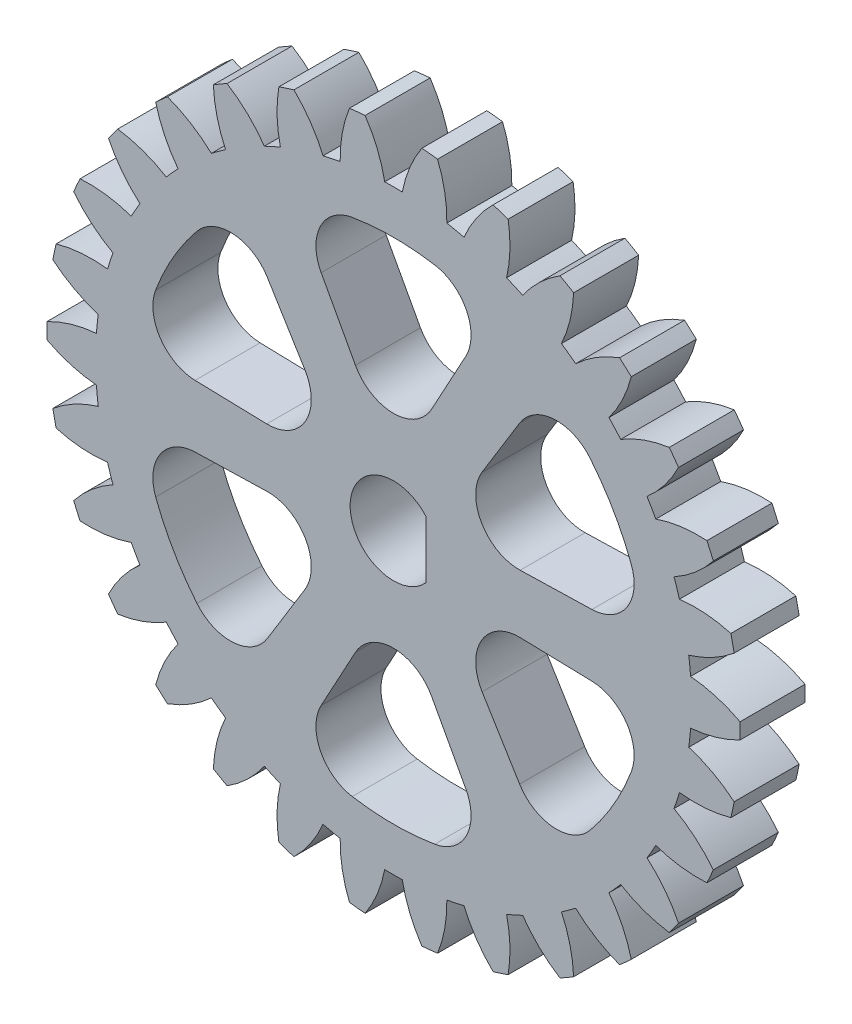
from build123d import *

# Parameters (mm, degrees)
SKETCH1_R                 = 16
BOSS_EXTRUDE1_DEPTH       = 3
CUT_EXTRUDE1_DEPTH        = 4
CIRPATTERN1_COUNT         = 30
CUT_EXTRUDE2_DEPTH        = 4
FILLET10_R                = 2
CIRPATTERN2_COUNT         = 6
FILLET10_OF_CIRPATTERN2_R = 2
CUT_EXTRUDE3_DEPTH        = 4


with BuildPart() as part:
    # Sketch1 → Boss-Extrude1 (new body)
    with BuildSketch(Plane.XY):
        Circle(SKETCH1_R)
    extrude(amount=BOSS_EXTRUDE1_DEPTH)

    # Sketch3 → Cut-Extrude1 (cut, through all)
    with BuildSketch(Plane.XY.offset(3)):
        with BuildLine():
            ThreePointArc((0.405262886, 13.744026411), (0, 13.75), (-0.405262886, 13.744026411))
            ThreePointArc((-0.405262886, 13.744026411), (-0.747286699, 14.890480207), (-1.309972212, 15.946283981))
            ThreePointArc((-1.309972212, 15.946283981), (0, 16), (1.309972212, 15.946283981))
            ThreePointArc((1.309972212, 15.946283981), (0.747286699, 14.890480207), (0.405262886, 13.744026411))
        make_face()
    cut_extrude1 = extrude(amount=-CUT_EXTRUDE1_DEPTH, mode=Mode.SUBTRACT)

    # CirPattern1: Cut-Extrude1 ×30 about axis
    cirpattern1_axis = Axis((0, 0, 0), (0, 0, 1))
    for i in range(1, CIRPATTERN1_COUNT):
        add(cut_extrude1.rotate(cirpattern1_axis, i * 360 / CIRPATTERN1_COUNT), mode=Mode.SUBTRACT)

    # Sketch4 → Cut-Extrude2 (cut, through all)
    with BuildSketch(Plane.XY.offset(3)):
        with BuildLine():
            Line((0, 2.5), (-4.520084972, 10.824960905))
            ThreePointArc((-4.520084972, 10.824960905), (0, 11.730769231), (4.520084972, 10.824960905))
            Line((4.520084972, 10.824960905), (0, 2.5))
        make_face()
    cut_extrude2 = extrude(amount=-CUT_EXTRUDE2_DEPTH, mode=Mode.SUBTRACT)

    # Fillet10
    fillet10_edges = [part.edges().sort_by_distance(p)[0] for p in [
        (4.520084972, 10.824960905, 1.5),
        (0, 2.5, 1.5),
        (-4.520084972, 10.824960905, 1.5),
    ]]
    fillet(fillet10_edges, radius=FILLET10_R)

    # CirPattern2: Cut-Extrude2 ×6 about axis
    cirpattern2_axis = Axis((0, 0, 0), (0, 0, 1))
    for i in range(1, CIRPATTERN2_COUNT):
        add(cut_extrude2.rotate(cirpattern2_axis, i * 360 / CIRPATTERN2_COUNT), mode=Mode.SUBTRACT)

    # Fillet10 of CirPattern2
    fillet10_of_cirpattern2_edges = [part.edges().sort_by_distance(p)[0] for p in [
        (-7.114648652, 9.326988866, 1.5),
        (-2.165063509, 1.25, 1.5),
        (-11.634733625, 1.497972039, 1.5),
        (-11.634733625, -1.497972039, 1.5),
        (-2.165063509, -1.25, 1.5),
        (-7.114648652, -9.326988866, 1.5),
        (-4.520084972, -10.824960905, 1.5),
        (0, -2.5, 1.5),
        (4.520084972, -10.824960905, 1.5),
        (7.114648652, -9.326988866, 1.5),
        (2.165063509, -1.25, 1.5),
        (11.634733625, -1.497972039, 1.5),
        (11.634733625, 1.497972039, 1.5),
        (2.165063509, 1.25, 1.5),
        (7.114648652, 9.326988866, 1.5),
    ]]
    fillet(fillet10_of_cirpattern2_edges, radius=FILLET10_OF_CIRPATTERN2_R)

    # Sketch5 → Cut-Extrude3 (cut, through all)
    with BuildSketch(Plane(origin=(0, 0, 0), x_dir=(-1, 0, 0), z_dir=(0, 0, -1))):
        with BuildLine():
            Line((-1.5, 1.322875656), (-1.5, -1.322875656))
            ThreePointArc((-1.5, -1.322875656), (2, 0), (-1.5, 1.322875656))
        make_face()
    extrude(amount=-CUT_EXTRUDE3_DEPTH, mode=Mode.SUBTRACT)


solid = part.part
